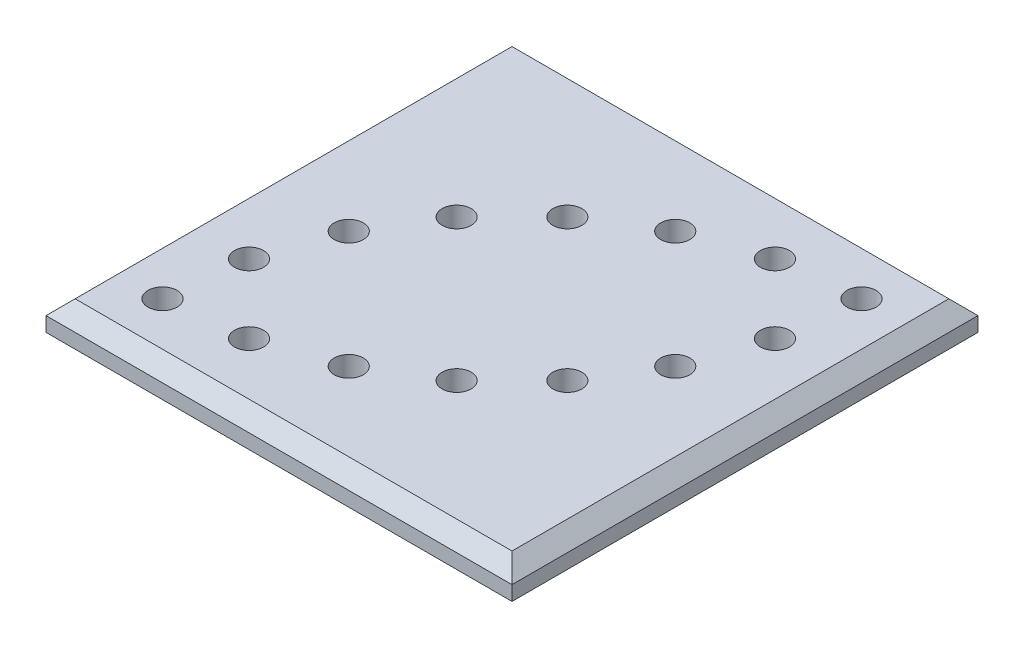
from build123d import *

# Parameters (mm, degrees)
SKETCH1_W                = 101.6
SKETCH1_H                = 101.6
BOSS_EXTRUDE1_DEPTH      = 9.525
SKETCH2_W                = 101.6
SKETCH2_H                = 101.6
SKETCH2_W_2              = 94.996
SKETCH2_H_2              = 94.996
CUT_EXTRUDE1_DEPTH       = 3.175
CHAMFER1_SIZE            = 3.175
SKETCH3_R                = 3.175
DIANA_HOLE_PATTERN_DEPTH = 10.525


with BuildPart() as part:
    # Sketch1 → Boss-Extrude1 (new body)
    with BuildSketch(Plane(origin=(0, 0, 0), x_dir=(1, 0, 0), z_dir=(0, 1, 0))):
        Rectangle(SKETCH1_W, SKETCH1_H)
    extrude(amount=BOSS_EXTRUDE1_DEPTH)

    # Sketch2 → Cut-Extrude1 (cut)
    with BuildSketch(Plane.XZ):
        Rectangle(SKETCH2_W, SKETCH2_H)
        Rectangle(SKETCH2_W_2, SKETCH2_H_2, mode=Mode.SUBTRACT)
    extrude(amount=-CUT_EXTRUDE1_DEPTH, mode=Mode.SUBTRACT)

    # Chamfer1
    chamfer1_edges = [part.edges().sort_by_distance(p)[0] for p in [
        (-50.8, 9.525, 0),
        (0, 9.525, 50.8),
        (50.8, 9.525, 0),
        (0, 9.525, -50.8),
    ]]
    chamfer(chamfer1_edges, length=CHAMFER1_SIZE)

    # Sketch3 → Diana Hole Pattern (cut, through all)
    with BuildSketch(Plane(origin=(0, 9.525, 0), x_dir=(1, 0, 0), z_dir=(0, 1, 0))):
        with Locations((21.143904833, 36.189506908)):
            Circle(SKETCH3_R)
        with Locations((5.038059079, 30.553827734)):
            Circle(SKETCH3_R)
        with Locations((-9.409922902, 21.475558964)):
            Circle(SKETCH3_R)
        with Locations((-21.475558964, 9.409922902)):
            Circle(SKETCH3_R)
        with Locations((-30.553827734, -5.038059079)):
            Circle(SKETCH3_R)
        with Locations((-36.189506908, -21.143904833)):
            Circle(SKETCH3_R)
        with Locations((-38.1, -38.1)):
            Circle(SKETCH3_R)
        with Locations((-21.143904833, -36.189506908)):
            Circle(SKETCH3_R)
        with Locations((-5.038059079, -30.553827734)):
            Circle(SKETCH3_R)
        with Locations((9.409922902, -21.475558964)):
            Circle(SKETCH3_R)
        with Locations((21.475558964, -9.409922902)):
            Circle(SKETCH3_R)
        with Locations((30.553827734, 5.038059079)):
            Circle(SKETCH3_R)
        with Locations((36.189506908, 21.143904833)):
            Circle(SKETCH3_R)
        with Locations((38.1, 38.1)):
            Circle(SKETCH3_R)
    extrude(amount=-DIANA_HOLE_PATTERN_DEPTH, mode=Mode.SUBTRACT)


solid = part.part
